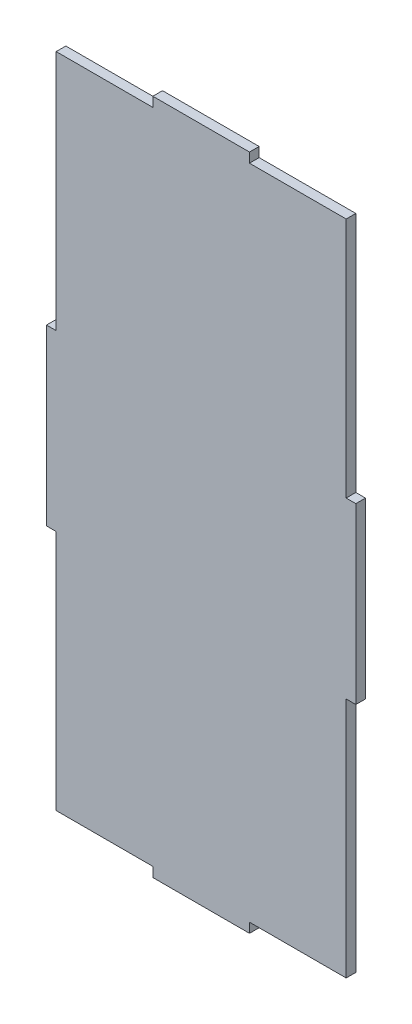
from build123d import *

# Parameters (mm, degrees)
SKETCH1_W                = 215.9
SKETCH1_H                = 457.2
BOSS_EXTRUDE1_DEPTH      = 6.35
CUT_EXTRUDE1_DEPTH       = 1
CUT_EXTRUDE1_DEPTH_BACK  = 7.35
CUT_EXTRUDE2_DEPTH       = 1
CUT_EXTRUDE2_DEPTH_BACK  = 7.35
CUT_EXTRUDE3_DEPTH       = 1
CUT_EXTRUDE3_DEPTH_BACK  = 7.35
CUT_EXTRUDE4_DEPTH       = 1
CUT_EXTRUDE4_DEPTH_BACK  = 7.35
CUT_EXTRUDE6_DEPTH       = 1
CUT_EXTRUDE6_DEPTH_BACK  = 7.35
CUT_EXTRUDE7_DEPTH       = 1
CUT_EXTRUDE7_DEPTH_BACK  = 7.35
CUT_EXTRUDE9_DEPTH       = 1
CUT_EXTRUDE9_DEPTH_BACK  = 7.35
CUT_EXTRUDE12_DEPTH      = 1
CUT_EXTRUDE12_DEPTH_BACK = 7.35
CUT_EXTRUDE13_DEPTH      = 7.35
CUT_EXTRUDE14_DEPTH      = 1
CUT_EXTRUDE14_DEPTH_BACK = 7.35
CUT_EXTRUDE15_DEPTH      = 1
CUT_EXTRUDE15_DEPTH_BACK = 7.35
CUT_EXTRUDE16_DEPTH      = 1
CUT_EXTRUDE16_DEPTH_BACK = 7.35


with BuildPart() as part:
    # Sketch1 → Boss-Extrude1 (new body)
    with BuildSketch(Plane.XY):
        with Locations((-336.112358352, 173.908620123)):
            Rectangle(SKETCH1_W, SKETCH1_H)
    extrude(amount=BOSS_EXTRUDE1_DEPTH)

    # Sketch3 → Cut-Extrude1 (cut, two sides)
    with BuildSketch(Plane.XY.offset(6.35)) as cut_extrude1_sk:
        Polygon((-1442.380242436, -41.991379877), (-444.062358352, -41.991379877), (-367.862358352, -41.991379877), (-367.862358352, -54.691379877), (-367.862358352, -1053.009263961), (-1736.075705676, -2507.15733996), (-2810.59358976, -1496.139455876), align=None)
    extrude(amount=CUT_EXTRUDE1_DEPTH, mode=Mode.SUBTRACT)
    extrude(cut_extrude1_sk.sketch, amount=-CUT_EXTRUDE1_DEPTH_BACK, mode=Mode.SUBTRACT)

    # Sketch4 → Cut-Extrude2 (cut, two sides)
    with BuildSketch(Plane.XY.offset(6.35)) as cut_extrude2_sk:
        Polygon((770.155525732, -41.991379877), (-228.162358352, -41.991379877), (-304.362358352, -41.991379877), (-304.362358352, -54.691379877), (-304.362358352, -1053.009263961), (1063.850988971, -2507.15733996), (2138.368873055, -1496.139455876), align=None)
    extrude(amount=CUT_EXTRUDE2_DEPTH, mode=Mode.SUBTRACT)
    extrude(cut_extrude2_sk.sketch, amount=-CUT_EXTRUDE2_DEPTH_BACK, mode=Mode.SUBTRACT)

    # Sketch5 → Cut-Extrude3 (cut, two sides)
    with BuildSketch(Plane.XY.offset(6.35)) as cut_extrude3_sk:
        Polygon((-1321.857723807, -48.341379877), (-367.862358352, -48.341379877), (-304.362358352, -48.341379877), (649.633007102, -48.341379877), (649.633007102, -1956.332110786), (-1321.857723807, -1956.332110786), align=None)
    extrude(amount=CUT_EXTRUDE3_DEPTH, mode=Mode.SUBTRACT)
    extrude(cut_extrude3_sk.sketch, amount=-CUT_EXTRUDE3_DEPTH_BACK, mode=Mode.SUBTRACT)

    # Sketch6 → Cut-Extrude4 (cut, two sides)
    with BuildSketch(Plane.XY.offset(6.35)) as cut_extrude4_sk:
        Polygon((-1430.972246725, 389.808620123), (-444.062358352, 389.808620123), (-367.862358352, 389.808620123), (-367.862358352, 402.508620123), (-367.862358352, 1389.418508496), (-1719.957069161, 2827.404740722), (-2783.066957534, 1827.79485235), align=None)
    extrude(amount=CUT_EXTRUDE4_DEPTH, mode=Mode.SUBTRACT)
    extrude(cut_extrude4_sk.sketch, amount=-CUT_EXTRUDE4_DEPTH_BACK, mode=Mode.SUBTRACT)

    # Sketch7 → Cut-Extrude6 (cut, two sides)
    with BuildSketch(Plane.XY.offset(6.35)) as cut_extrude6_sk:
        Polygon((758.74753002, 389.808620123), (-228.162358352, 389.808620123), (-304.362358352, 389.808620123), (-304.362358352, 402.508620123), (-304.362358352, 1389.418508496), (1047.732352456, 2827.404740722), (2110.842240829, 1827.79485235), align=None)
    extrude(amount=CUT_EXTRUDE6_DEPTH, mode=Mode.SUBTRACT)
    extrude(cut_extrude6_sk.sketch, amount=-CUT_EXTRUDE6_DEPTH_BACK, mode=Mode.SUBTRACT)

    # Sketch8 → Cut-Extrude7 (cut, two sides)
    with BuildSketch(Plane.XY.offset(6.35)) as cut_extrude7_sk:
        Polygon((637.509607102, 396.158620123), (-304.362358352, 396.158620123), (-367.862358352, 396.158620123), (-1309.734323807, 396.158620123), (-1309.734323807, 2279.902551032), (637.509607102, 2279.902551032), align=None)
    extrude(amount=CUT_EXTRUDE7_DEPTH, mode=Mode.SUBTRACT)
    extrude(cut_extrude7_sk.sketch, amount=-CUT_EXTRUDE7_DEPTH_BACK, mode=Mode.SUBTRACT)

    # Sketch9 → Cut-Extrude9 (cut, two sides)
    with BuildSketch(Plane.XY.offset(6.35)) as cut_extrude9_sk:
        Polygon((-240.862358352, -1017.943060863), (-240.862358352, -41.991379877), (-240.862358352, 116.758620123), (-228.162358352, 116.758620123), (747.789322634, 116.758620123), (2219.450453951, -1165.481704095), (1230.798772964, -2300.183385081), align=None)
    extrude(amount=CUT_EXTRUDE9_DEPTH, mode=Mode.SUBTRACT)
    extrude(cut_extrude9_sk.sketch, amount=-CUT_EXTRUDE9_DEPTH_BACK, mode=Mode.SUBTRACT)

    # Sketch10 → Cut-Extrude12 (cut, two sides)
    with BuildSketch(Plane.XY.offset(6.35)) as cut_extrude12_sk:
        Polygon((-240.862358352, 1365.760301109), (-240.862358352, 389.808620123), (-240.862358352, 231.058620123), (-228.162358352, 231.058620123), (747.789322634, 231.058620123), (2219.450453951, 1513.298944341), (1230.798772964, 2648.000625327), align=None)
    extrude(amount=CUT_EXTRUDE12_DEPTH, mode=Mode.SUBTRACT)
    extrude(cut_extrude12_sk.sketch, amount=-CUT_EXTRUDE12_DEPTH_BACK, mode=Mode.SUBTRACT)

    # Sketch12 → Cut-Extrude13 (cut, through all)
    with BuildSketch(Plane.XY.offset(6.35)):
        Polygon((-234.512358352, 939.558620123), (-234.512358352, 231.058620123), (-234.512358352, 116.758620123), (-234.512358352, -591.741379877), (1182.487641648, -591.741379877), (1182.487641648, 939.558620123), align=None)
    extrude(amount=-CUT_EXTRUDE13_DEPTH, mode=Mode.SUBTRACT)

    # Sketch13 → Cut-Extrude14 (cut, two sides)
    with BuildSketch(Plane.XY.offset(6.35)) as cut_extrude14_sk:
        Polygon((-431.362358352, -1012.66894285), (-431.362358352, -41.991379877), (-431.362358352, 116.758620123), (-444.062358352, 116.758620123), (-1414.739921325, 116.758620123), (-2878.883865855, -1158.052046108), (-1895.506302882, -2287.479609081), align=None)
    extrude(amount=CUT_EXTRUDE14_DEPTH, mode=Mode.SUBTRACT)
    extrude(cut_extrude14_sk.sketch, amount=-CUT_EXTRUDE14_DEPTH_BACK, mode=Mode.SUBTRACT)

    # Sketch14 → Cut-Extrude15 (cut, two sides)
    with BuildSketch(Plane.XY.offset(6.35)) as cut_extrude15_sk:
        Polygon((-431.362358352, 1360.486183096), (-431.362358352, 389.808620123), (-431.362358352, 231.058620123), (-444.062358352, 231.058620123), (-1414.739921325, 231.058620123), (-2878.883865855, 1505.869286354), (-1895.506302882, 2635.296849327), align=None)
    extrude(amount=CUT_EXTRUDE15_DEPTH, mode=Mode.SUBTRACT)
    extrude(cut_extrude15_sk.sketch, amount=-CUT_EXTRUDE15_DEPTH_BACK, mode=Mode.SUBTRACT)

    # Sketch16 → Cut-Extrude16 (cut, two sides)
    with BuildSketch(Plane.XY.offset(6.35)) as cut_extrude16_sk:
        Polygon((-437.712358352, 932.013321967), (-437.712358352, 231.058620123), (-437.712358352, 116.758620123), (-437.712358352, -584.196081721), (-1839.62176204, -584.196081721), (-1839.62176204, 932.013321967), align=None)
    extrude(amount=CUT_EXTRUDE16_DEPTH, mode=Mode.SUBTRACT)
    extrude(cut_extrude16_sk.sketch, amount=-CUT_EXTRUDE16_DEPTH_BACK, mode=Mode.SUBTRACT)


solid = part.part
